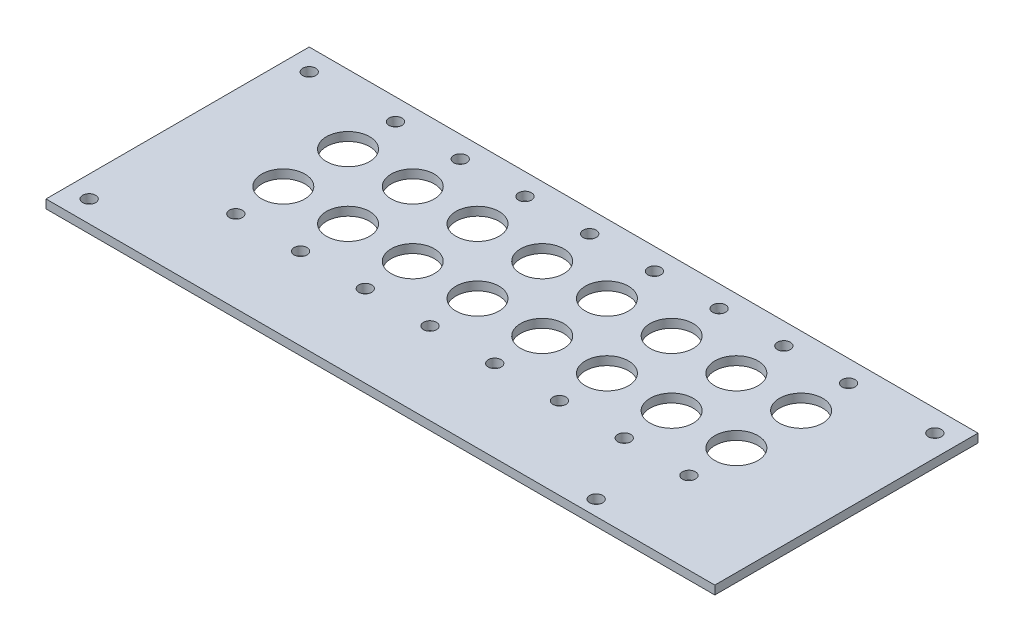
from build123d import *

# Parameters (mm, degrees)
ESQUISSE1_W        = 155
ESQUISSE1_H        = 61
ESQUISSE1_R        = 5
ESQUISSE1_R_2      = 1.5
BOSS_EXTRU_2_DEPTH = 2


with BuildPart() as part:
    # Esquisse1 → Boss.-Extru.2 (new body)
    with BuildSketch(Plane(origin=(0, 0, 0), x_dir=(1, 0, 0), z_dir=(0, 1, 0))):
        Rectangle(ESQUISSE1_W, ESQUISSE1_H)
        with Locations((-52.5, 14.5)):
            Circle(ESQUISSE1_R, mode=Mode.SUBTRACT)
        with Locations((-37.5, 14.5)):
            Circle(ESQUISSE1_R, mode=Mode.SUBTRACT)
        with Locations((-22.5, 14.5)):
            Circle(ESQUISSE1_R, mode=Mode.SUBTRACT)
        with Locations((-7.5, 14.5)):
            Circle(ESQUISSE1_R, mode=Mode.SUBTRACT)
        with Locations((7.5, 14.5)):
            Circle(ESQUISSE1_R, mode=Mode.SUBTRACT)
        with Locations((22.5, 14.5)):
            Circle(ESQUISSE1_R, mode=Mode.SUBTRACT)
        with Locations((37.5, 14.5)):
            Circle(ESQUISSE1_R, mode=Mode.SUBTRACT)
        with Locations((52.5, 14.5)):
            Circle(ESQUISSE1_R, mode=Mode.SUBTRACT)
        with Locations((-37.5, -0.5)):
            Circle(ESQUISSE1_R, mode=Mode.SUBTRACT)
        with Locations((-22.5, -0.5)):
            Circle(ESQUISSE1_R, mode=Mode.SUBTRACT)
        with Locations((-7.5, -0.5)):
            Circle(ESQUISSE1_R, mode=Mode.SUBTRACT)
        with Locations((7.5, -0.5)):
            Circle(ESQUISSE1_R, mode=Mode.SUBTRACT)
        with Locations((22.5, -0.5)):
            Circle(ESQUISSE1_R, mode=Mode.SUBTRACT)
        with Locations((37.5, -0.5)):
            Circle(ESQUISSE1_R, mode=Mode.SUBTRACT)
        with Locations((52.5, -0.5)):
            Circle(ESQUISSE1_R, mode=Mode.SUBTRACT)
        with Locations((-52.5, -0.5)):
            Circle(ESQUISSE1_R, mode=Mode.SUBTRACT)
        with Locations((-52.5, 25.5)):
            Circle(ESQUISSE1_R_2, mode=Mode.SUBTRACT)
        with Locations((-37.5, 25.5)):
            Circle(ESQUISSE1_R_2, mode=Mode.SUBTRACT)
        with Locations((-22.5, 25.5)):
            Circle(ESQUISSE1_R_2, mode=Mode.SUBTRACT)
        with Locations((-7.5, 25.5)):
            Circle(ESQUISSE1_R_2, mode=Mode.SUBTRACT)
        with Locations((7.5, 25.5)):
            Circle(ESQUISSE1_R_2, mode=Mode.SUBTRACT)
        with Locations((22.5, 25.5)):
            Circle(ESQUISSE1_R_2, mode=Mode.SUBTRACT)
        with Locations((37.5, 25.5)):
            Circle(ESQUISSE1_R_2, mode=Mode.SUBTRACT)
        with Locations((52.5, 25.5)):
            Circle(ESQUISSE1_R_2, mode=Mode.SUBTRACT)
        with Locations((-52.5, -11.5)):
            Circle(ESQUISSE1_R_2, mode=Mode.SUBTRACT)
        with Locations((-37.5, -11.5)):
            Circle(ESQUISSE1_R_2, mode=Mode.SUBTRACT)
        with Locations((-22.5, -11.5)):
            Circle(ESQUISSE1_R_2, mode=Mode.SUBTRACT)
        with Locations((-7.5, -11.5)):
            Circle(ESQUISSE1_R_2, mode=Mode.SUBTRACT)
        with Locations((7.5, -11.5)):
            Circle(ESQUISSE1_R_2, mode=Mode.SUBTRACT)
        with Locations((22.5, -11.5)):
            Circle(ESQUISSE1_R_2, mode=Mode.SUBTRACT)
        with Locations((37.5, -11.5)):
            Circle(ESQUISSE1_R_2, mode=Mode.SUBTRACT)
        with Locations((52.5, -11.5)):
            Circle(ESQUISSE1_R_2, mode=Mode.SUBTRACT)
        with Locations((46.5, -27)):
            Circle(ESQUISSE1_R_2, mode=Mode.SUBTRACT)
        with Locations((-72.5, 25.5)):
            Circle(ESQUISSE1_R_2, mode=Mode.SUBTRACT)
        with Locations((-72.5, -25.5)):
            Circle(ESQUISSE1_R_2, mode=Mode.SUBTRACT)
        with Locations((72.5, 25.5)):
            Circle(ESQUISSE1_R_2, mode=Mode.SUBTRACT)
    extrude(amount=BOSS_EXTRU_2_DEPTH)


solid = part.part
